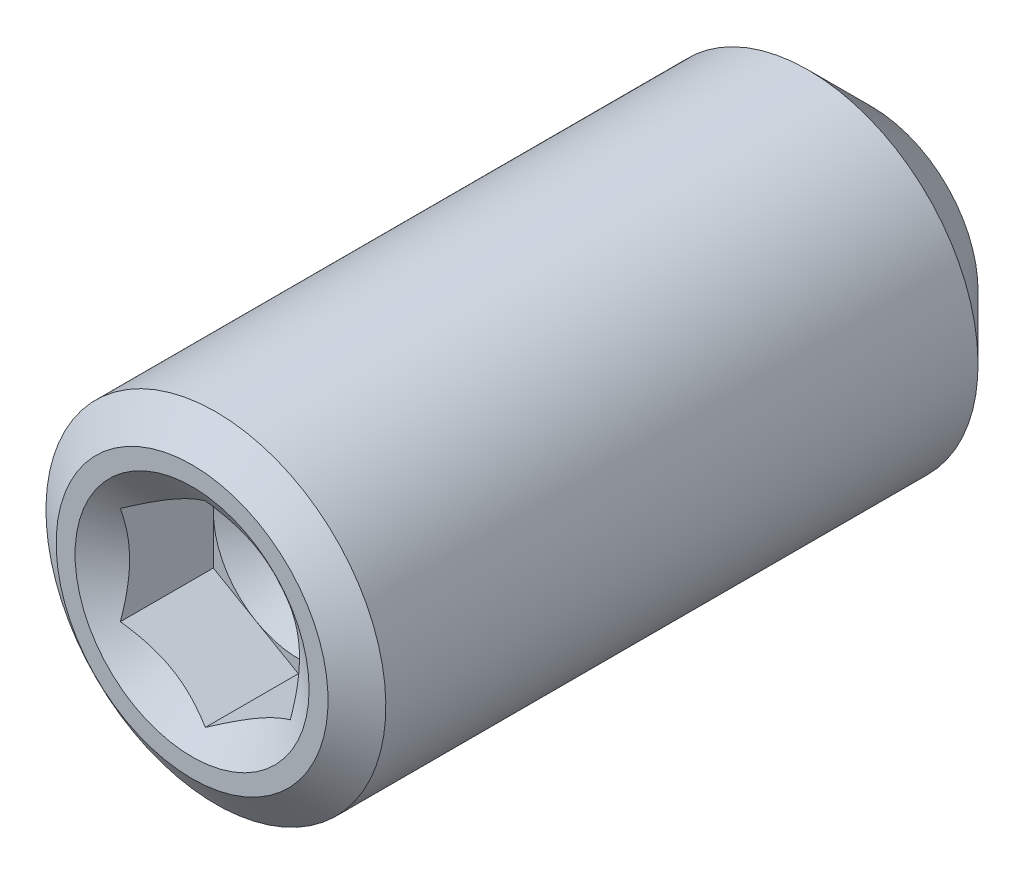
from build123d import *

# Parameters (mm, degrees)
CUT_EXTRUDE3_DEPTH = 0.9375


with BuildPart() as part:
    # Sketch4 → Revolve1 (revolve)
    with BuildSketch(Plane(origin=(0, 0, 0), x_dir=(0, 0, -1), z_dir=(1, 0, 0))):
        with BuildLine():
            Line((2.780834109, 0), (3.112041367, 0.551221444))
            ThreePointArc((3.112041367, 0.551221444), (3.191888731, 0.737071218), (3.219165891, 0.9375))
            Line((3.219165891, 0.9375), (2.656665891, 1.5))
            Line((2.656665891, 1.5), (-2.570771847, 1.5))
            Line((-2.570771847, 1.5), (-2.780834109, 1.2))
            Line((-2.780834109, 1.2), (-2.780834109, 0))
            Line((-2.780834109, 0), (2.780834109, 0))
        make_face()
    revolve(axis=Axis((0, 0, -2.780834109), (0, 0, 1)))

    # Sketch6 → Cut-Extrude3 (cut)
    with BuildSketch(Plane.XY.offset(2.780834109)):
        Polygon((0.75, 0.433012702), (0, 0.866025404), (-0.75, 0.433012702), (-0.75, -0.433012702), (0, -0.866025404), (0.75, -0.433012702), align=None)
    extrude(amount=-CUT_EXTRUDE3_DEPTH, mode=Mode.SUBTRACT)

    # Cut-Extrude4 cone 1 section (through the dimple's axis) → Cut-Extrude4 (revolve, cut)
    with BuildSketch(Plane(origin=(0, 0, 2.780834109), x_dir=(0, -1, 0), z_dir=(1, 0, 0))):
        Polygon((0, 0), (1.033012702, 0), (0, 0.723323281), align=None)
    revolve(axis=Axis((0, 0, 2.780834109), (0, 0, -1)), mode=Mode.SUBTRACT)

    # Cut-Extrude5 cone 1 section (through the dimple's axis) → Cut-Extrude5 (revolve, cut)
    with BuildSketch(Plane(origin=(0, 0, 1.843334109), x_dir=(0, -1, 0), z_dir=(1, 0, 0))):
        Polygon((0, 0), (0.75, 0), (0, 0.433012702), align=None)
    revolve(axis=Axis((0, 0, 1.843334109), (0, 0, -1)), mode=Mode.SUBTRACT)


solid = part.part
